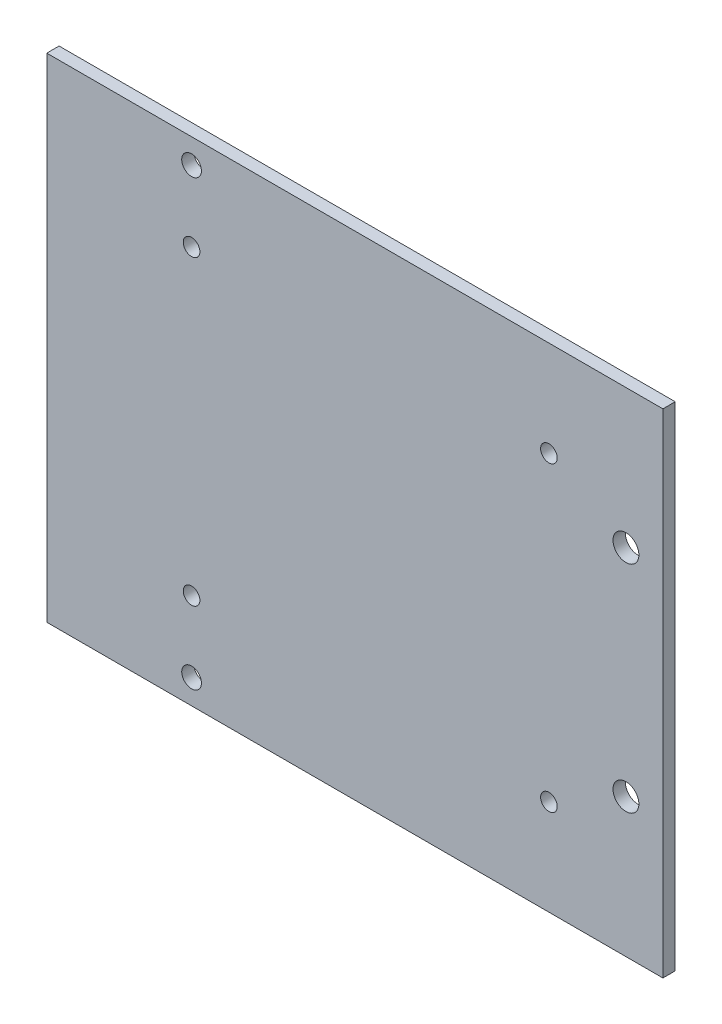
from build123d import *

# Parameters (mm, degrees)
SKETCH_1_W          = 100
SKETCH_1_H          = 80
EXTRUDE_1_DEPTH     = 2
SKETCH_3_R          = 1.35
CUT_EXTRUDE_1_DEPTH = 3
SKETCH_4_R          = 1.6
CUT_EXTRUDE_2_DEPTH = 3
SKETCH_5_R          = 1.6
CUT_EXTRUDE_3_DEPTH = 3
SKETCH_7_R          = 2.1
CUT_EXTRUDE_5_DEPTH = 10


with BuildPart() as part:
    # 草图1 → 凸台-拉伸1 (new body)
    with BuildSketch(Plane.XY):
        Rectangle(SKETCH_1_W, SKETCH_1_H)
    extrude(amount=EXTRUDE_1_DEPTH)

    # 草图3 → 切除-拉伸1 (cut, through all)
    with BuildSketch(Plane.XY.offset(2)):
        with Locations((-26.5, -24.5)):
            Circle(SKETCH_3_R)
        with Locations((-26.5, 24.5)):
            Circle(SKETCH_3_R)
        with Locations((31.5, 24.5)):
            Circle(SKETCH_3_R)
        with Locations((31.5, -24.5)):
            Circle(SKETCH_3_R)
    extrude(amount=-CUT_EXTRUDE_1_DEPTH, mode=Mode.SUBTRACT)

    # 草图4 → 切除-拉伸2 (cut, through all)
    with BuildSketch(Plane(origin=(0, 0, 0), x_dir=(-1, 0, 0), z_dir=(0, 0, -1))):
        with Locations((26.5, -36)):
            Circle(SKETCH_4_R)
    extrude(amount=-CUT_EXTRUDE_2_DEPTH, mode=Mode.SUBTRACT)

    # 草图5 → 切除-拉伸3 (cut, through all)
    with BuildSketch(Plane.XY.offset(2)):
        with Locations((-26.5, 36)):
            Circle(SKETCH_5_R)
    extrude(amount=-CUT_EXTRUDE_3_DEPTH, mode=Mode.SUBTRACT)

    # 草图7 → 切除-拉伸5 (cut)
    with BuildSketch(Plane.XY.offset(2)):
        with Locations((44, 17.5)):
            Circle(SKETCH_7_R)
        with Locations((44, -17.5)):
            Circle(SKETCH_7_R)
    extrude(amount=-CUT_EXTRUDE_5_DEPTH, mode=Mode.SUBTRACT)


solid = part.part
